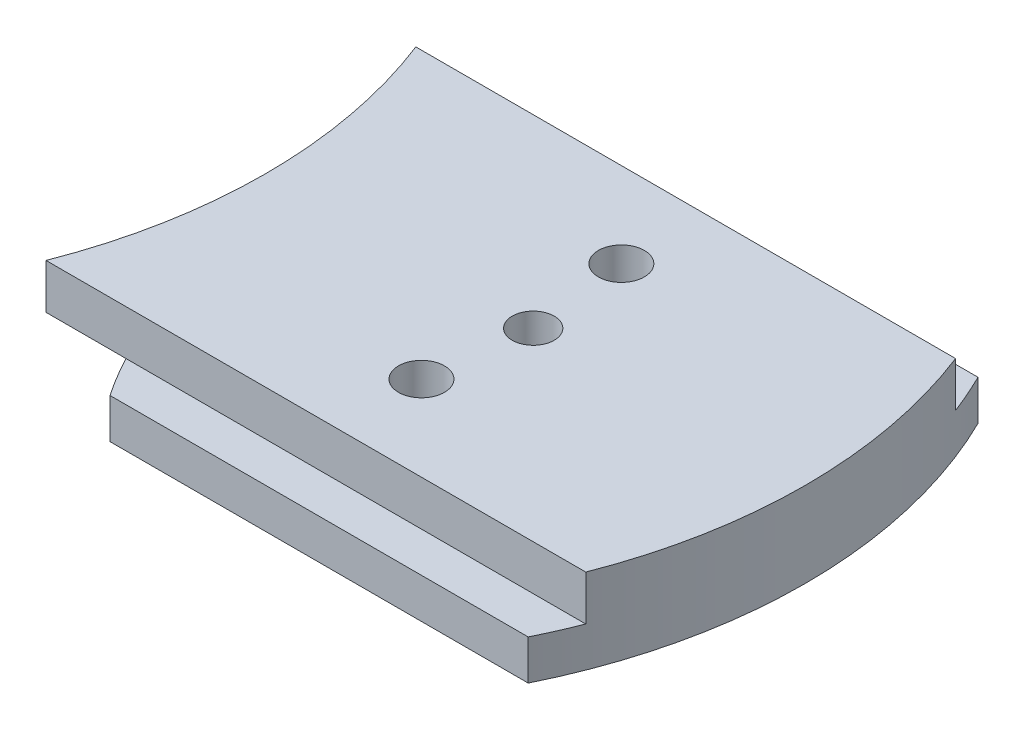
from build123d import *

# Parameters (mm, degrees)
SKETCH_1_R          = 1.05
EXTRUDE_1_DEPTH     = 2
EXTRUDE_START       = 2
SKETCH_1_3_R        = 1.05
EXTRUDE_2_DEPTH     = 2.25
CUT_EXTRUDE_1_DEPTH = 2
SKETCH_3_R          = 1.15
CUT_EXTRUDE_2_DEPTH = 5.25
CHAMFER_1_SIZE      = 1.2


with BuildPart() as part:
    # Эскиз1 → Бобышка-Вытянуть1 (new body)
    with BuildSketch(Plane(origin=(0, 0, 0), x_dir=(1, 0, 0), z_dir=(0, 1, 0))):
        with BuildLine():
            Line((0.878934798, 22.5), (0.878934798, 20.5))
            ThreePointArc((0.878934798, 20.5), (2.615780546, 11.25), (0.878934798, 2))
            Line((0.878934798, 2), (0.878934798, 0))
            Line((0.878934798, 0), (27, 0))
            ThreePointArc((27, 0), (29.615780546, 11.25), (27, 22.5))
            Line((27, 22.5), (0.878934798, 22.5))
        make_face()
        with Locations((16, 11.25)):
            Circle(SKETCH_1_R, mode=Mode.SUBTRACT)
    extrude(amount=EXTRUDE_1_DEPTH)

    # Эскиз1<3> → Бобышка-Вытянуть2 (add)
    with BuildSketch(Plane(origin=(0, 0, 0), x_dir=(1, 0, 0), z_dir=(0, 1, 0)).offset(EXTRUDE_START)):
        with BuildLine():
            Line((27.878934798, 20.5), (0.878934798, 20.5))
            ThreePointArc((0.878934798, 20.5), (2.615780546, 11.25), (0.878934798, 2))
            Line((0.878934798, 2), (27.878934798, 2))
            ThreePointArc((27.878934798, 2), (29.615780546, 11.25), (27.878934798, 20.5))
        make_face()
        with Locations((16, 11.25)):
            Circle(SKETCH_1_3_R, mode=Mode.SUBTRACT)
    extrude(amount=EXTRUDE_2_DEPTH)

    # Эскиз2 → Вырез-Вытянуть1 (cut)
    with BuildSketch(Plane.XZ):
        with BuildLine():
            Line((6.079834852, 0), (0.878934798, 0))
            Line((0.878934798, 0), (0.878934798, -22.5))
            Line((0.878934798, -22.5), (6.079834852, -22.5))
            ThreePointArc((6.079834852, -22.5), (2.615780546, -11.25), (6.079834852, 0))
        make_face()
    extrude(amount=-CUT_EXTRUDE_1_DEPTH, mode=Mode.SUBTRACT)

    # Эскиз3 → Вырез-Вытянуть2 (cut, through all)
    with BuildSketch(Plane(origin=(0, 4.25, 0), x_dir=(1, 0, 0), z_dir=(0, 1, 0))):
        with Locations((15.410523666, 6.25)):
            Circle(SKETCH_3_R)
        with Locations((15.410523666, 16.25)):
            Circle(SKETCH_3_R)
    extrude(amount=-CUT_EXTRUDE_2_DEPTH, mode=Mode.SUBTRACT)

    # Фаска1
    chamfer_1_edges = [part.edges().sort_by_distance(p)[0] for p in [
        (14.260523666, 0, -16.25),
        (14.260523666, 0, -6.25),
    ]]
    chamfer(chamfer_1_edges, length=CHAMFER_1_SIZE)


solid = part.part
